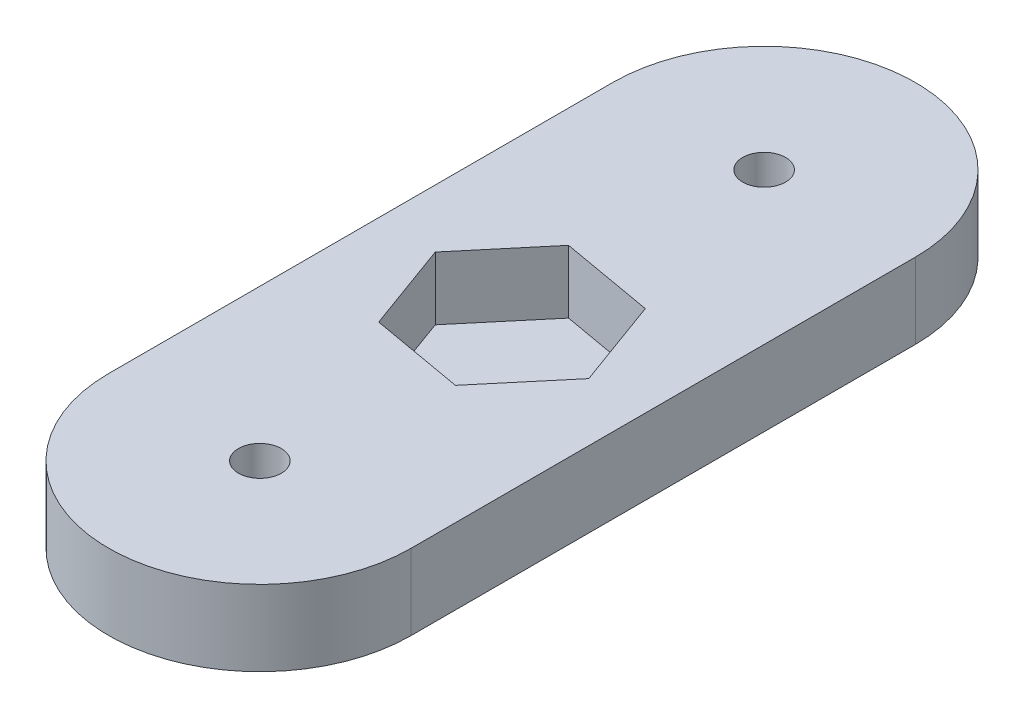
from build123d import *

# Parameters (mm, degrees)
SKETCH1_R           = 1.7
BOSS_EXTRUDE1_DEPTH = 6
CUT_EXTRUDE1_DEPTH  = 5


with BuildPart() as part:
    # Sketch1 → Boss-Extrude1 (new body)
    with BuildSketch(Plane(origin=(0, 0, 0), x_dir=(1, 0, 0), z_dir=(0, 1, 0))):
        with BuildLine():
            Line((-12, 0), (-12, 40))
            ThreePointArc((-12, 40), (0, 52), (12, 40))
            Line((12, 40), (12, 0))
            ThreePointArc((12, 0), (0, -12), (-12, 0))
        make_face()
        with Locations((0, 40)):
            Circle(SKETCH1_R, mode=Mode.SUBTRACT)
        Circle(SKETCH1_R, mode=Mode.SUBTRACT)
    extrude(amount=BOSS_EXTRUDE1_DEPTH)

    # Sketch2 → Cut-Extrude1 (cut)
    with BuildSketch(Plane(origin=(0, 6, 0), x_dir=(1, 0, 0), z_dir=(0, 1, 0))):
        Polygon((2.567050484, 12.947086762), (7.391527277, 18.696674312), (4.824476793, 25.749587551), (-2.567050484, 27.052913238), (-7.391527277, 21.303325688), (-4.824476793, 14.250412449), align=None)
    extrude(amount=-CUT_EXTRUDE1_DEPTH, mode=Mode.SUBTRACT)


solid = part.part
